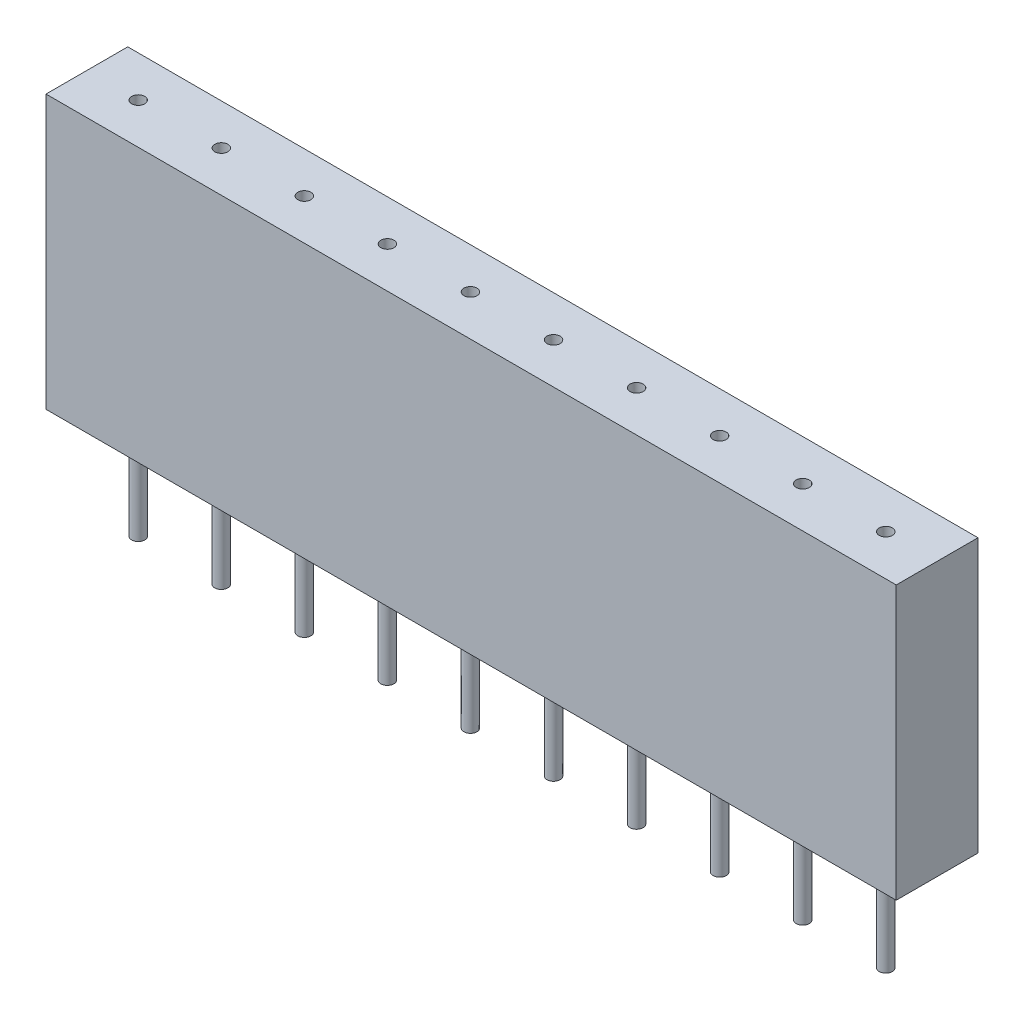
from build123d import *

# Parameters (mm, degrees)
SKETCH1_W           = 26
SKETCH1_H           = 2.5
BOSS_EXTRUDE1_DEPTH = 8.35
SKETCH2_R           = 0.2
CUT_EXTRUDE1_DEPTH  = 3
SKETCH3_R           = 0.2
BOSS_EXTRUDE2_DEPTH = 3.2
LPATTERN1_COUNT     = 10
LPATTERN1_PITCH     = 2.54


with BuildPart() as part:
    # Sketch1 → Boss-Extrude1 (new body)
    with BuildSketch(Plane(origin=(0, 0, 0), x_dir=(1, 0, 0), z_dir=(0, 1, 0))):
        Rectangle(SKETCH1_W, SKETCH1_H)
    extrude(amount=BOSS_EXTRUDE1_DEPTH)

    # Sketch2 → Cut-Extrude1 (cut)
    with BuildSketch(Plane(origin=(0, 8.35, 0), x_dir=(1, 0, 0), z_dir=(0, 1, 0))):
        with Locations((-11.43, 0)):
            Circle(SKETCH2_R)
    cut_extrude1 = extrude(amount=-CUT_EXTRUDE1_DEPTH, mode=Mode.SUBTRACT)

    # Sketch3 → Boss-Extrude2 (add)
    with BuildSketch(Plane.XZ):
        with Locations((-11.43, 0)):
            Circle(SKETCH3_R)
    boss_extrude2 = extrude(amount=BOSS_EXTRUDE2_DEPTH)

    # LPattern1: Cut-Extrude1, Boss-Extrude2 ×10
    with Locations(*[(i * LPATTERN1_PITCH, 0, 0) for i in range(1, LPATTERN1_COUNT)]):
        add(cut_extrude1, mode=Mode.SUBTRACT)
        add(boss_extrude2)


solid = part.part
